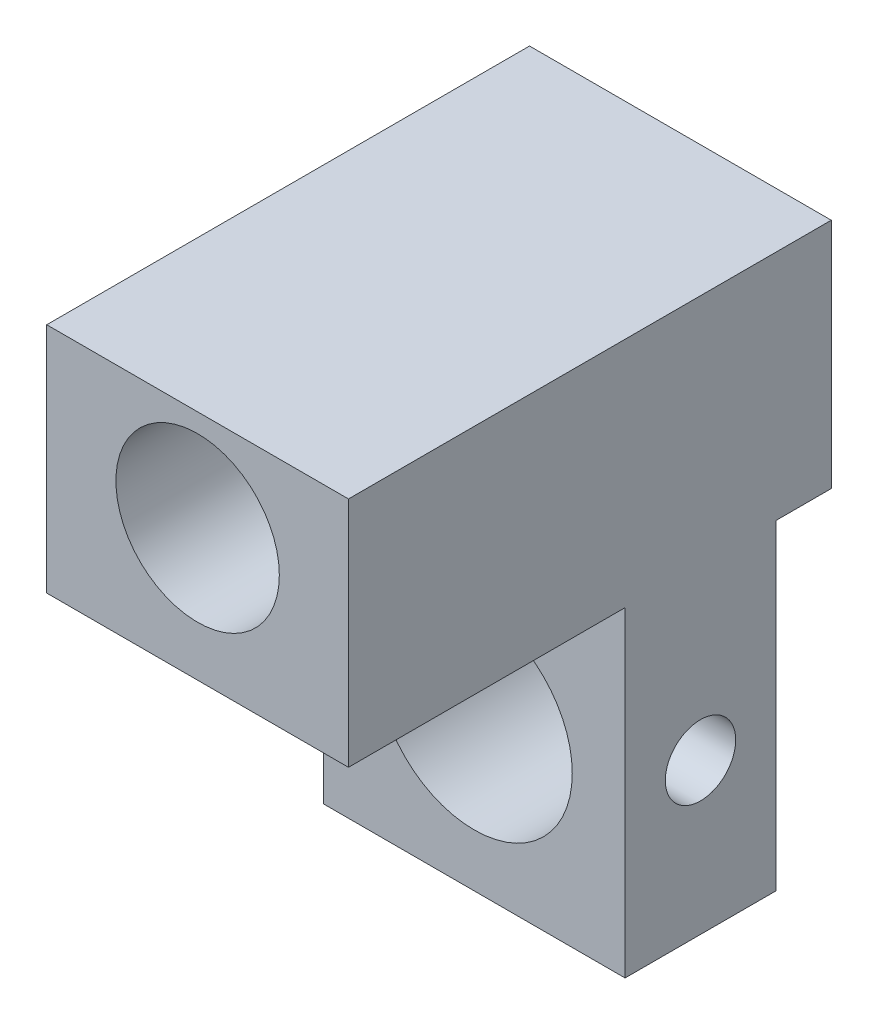
from build123d import *

# Parameters (mm, degrees)
ESQUISSE1_W             = 12
ESQUISSE1_H             = 24
BOSS_EXTRU_1_DEPTH      = 6
ESQUISSE3_R             = 3.25
ENL_V_MAT_EXTRU_1_DEPTH = 10
ESQUISSE2_R             = 3.9
ENL_V_MAT_EXTRU_2_DEPTH = 10
ESQUISSE5_R             = 1.4
ENL_V_MAT_EXTRU_3_DEPTH = 22
ESQUISSE6_R             = 4.5
ESQUISSE6_R_2           = 3.25
BOSS_EXTRU_4_DEPTH      = 0.1
ESQUISSE8_W             = 21.223716878
ESQUISSE8_H             = 12.113313322
ENL_V_MAT_EXTRU_4_DEPTH = 19
ESQUISSE9_R             = 1.625
ENL_V_MAT_EXTRU_5_DEPTH = 19
ESQUISSE4_R             = 5
ESQUISSE4_R_2           = 3.25
BOSS_EXTRU_5_DEPTH      = 11
ESQUISSE11_W            = 12
ESQUISSE11_H            = 11.243517906
ESQUISSE11_R            = 3.25
BOSS_EXTRU_6_DEPTH      = 2.2
BOSS_EXTRU_6_DEPTH_BACK = 17
ESQUISSE12_W            = 21.1
ESQUISSE12_H            = 2
ENL_V_MAT_EXTRU_6_DEPTH = 13.1


with BuildPart() as part:
    # Esquisse1 → Boss.-Extru.1 (new body)
    with BuildSketch(Plane.XY):
        Rectangle(ESQUISSE1_W, ESQUISSE1_H)
    extrude(amount=BOSS_EXTRU_1_DEPTH)

    # Esquisse3 → Enlèv. mat.-Extru.1 (cut)
    with BuildSketch(Plane.XY.offset(6)):
        with Locations((0, 6)):
            Circle(ESQUISSE3_R)
    extrude(amount=-ENL_V_MAT_EXTRU_1_DEPTH, mode=Mode.SUBTRACT)

    # Esquisse2 → Enlèv. mat.-Extru.2 (cut)
    with BuildSketch(Plane.XY.offset(6)):
        with Locations((0, -6)):
            Circle(ESQUISSE2_R)
    extrude(amount=-ENL_V_MAT_EXTRU_2_DEPTH, mode=Mode.SUBTRACT)

    # Esquisse5 → Enlèv. mat.-Extru.3 (cut)
    with BuildSketch(Plane(origin=(6, 0, 0), x_dir=(0, 0, -1), z_dir=(1, 0, 0))):
        with Locations((-3, -6)):
            Circle(ESQUISSE5_R)
    extrude(amount=-ENL_V_MAT_EXTRU_3_DEPTH, mode=Mode.SUBTRACT)

    # Esquisse6 → Boss.-Extru.4 (add)
    with BuildSketch(Plane(origin=(0, 0, 0), x_dir=(-1, 0, 0), z_dir=(0, 0, -1))):
        with Locations((0, 6)):
            Circle(ESQUISSE6_R)
        with Locations(Location((0, 6, 0), (0, 0, 180))):
            Circle(ESQUISSE6_R_2, mode=Mode.SUBTRACT)
    extrude(amount=BOSS_EXTRU_4_DEPTH)

    # Esquisse7 → Révolution1 (revolve)
    with BuildSketch(Plane(origin=(0, 0, 0), x_dir=(0, 0, -1), z_dir=(1, 0, 0)), mode=Mode.PRIVATE) as r_volution1_sk:
        with BuildLine():
            Line((0.1, 10.5), (0.1, 9.25))
            ThreePointArc((0.1, 9.25), (2.398097039, 8.298097039), (3.35, 6))
            Line((3.35, 6), (4.6, 6))
            ThreePointArc((4.6, 6), (3.281980515, 9.181980515), (0.1, 10.5))
        make_face()
    revolve(r_volution1_sk.sketch.rotate(Axis((0, 6, -0.1), (0, 0, -1)), 90), axis=Axis((0, 6, -0.1), (0, 0, -1)))

    # Esquisse8 → Enlèv. mat.-Extru.4 (cut)
    with BuildSketch(Plane(origin=(6, 0, 0), x_dir=(0, 0, -1), z_dir=(1, 0, 0))):
        with Locations((12.811858439, 6.195094528)):
            Rectangle(ESQUISSE8_W, ESQUISSE8_H)
    extrude(amount=-ENL_V_MAT_EXTRU_4_DEPTH, mode=Mode.SUBTRACT)

    # Esquisse9 → Enlèv. mat.-Extru.5 (cut)
    with BuildSketch(Plane(origin=(6, 0, 0), x_dir=(0, 0, -1), z_dir=(1, 0, 0))):
        with Locations((-3, 6)):
            Circle(ESQUISSE9_R)
    extrude(amount=-ENL_V_MAT_EXTRU_5_DEPTH, mode=Mode.SUBTRACT)

    # Esquisse4 → Boss.-Extru.5 (add)
    with BuildSketch(Plane.XY.offset(6)):
        with Locations(Location((0, 6, 0), (0, 0, 180))):
            Circle(ESQUISSE4_R)
        with Locations((0, 6)):
            Circle(ESQUISSE4_R_2, mode=Mode.SUBTRACT)
    extrude(amount=BOSS_EXTRU_5_DEPTH)

    # Esquisse11 → Boss.-Extru.6 (add, two sides)
    with BuildSketch(Plane(origin=(0, 0, 0), x_dir=(-1, 0, 0), z_dir=(0, 0, -1))) as boss_extru_6_sk:
        with Locations((0, 6.378241047)):
            Rectangle(ESQUISSE11_W, ESQUISSE11_H)
        with Locations(Location((0, 6, 0), (0, 0, 180))):
            Circle(ESQUISSE11_R, mode=Mode.SUBTRACT)
    extrude(amount=BOSS_EXTRU_6_DEPTH)
    extrude(boss_extru_6_sk.sketch, amount=-BOSS_EXTRU_6_DEPTH_BACK)

    # Esquisse12 → Enlèv. mat.-Extru.6 (cut)
    with BuildSketch(Plane.ZY.offset(6)):
        with Locations((6.45, 11)):
            Rectangle(ESQUISSE12_W, ESQUISSE12_H)
    extrude(amount=-ENL_V_MAT_EXTRU_6_DEPTH, mode=Mode.SUBTRACT)


solid = part.part
